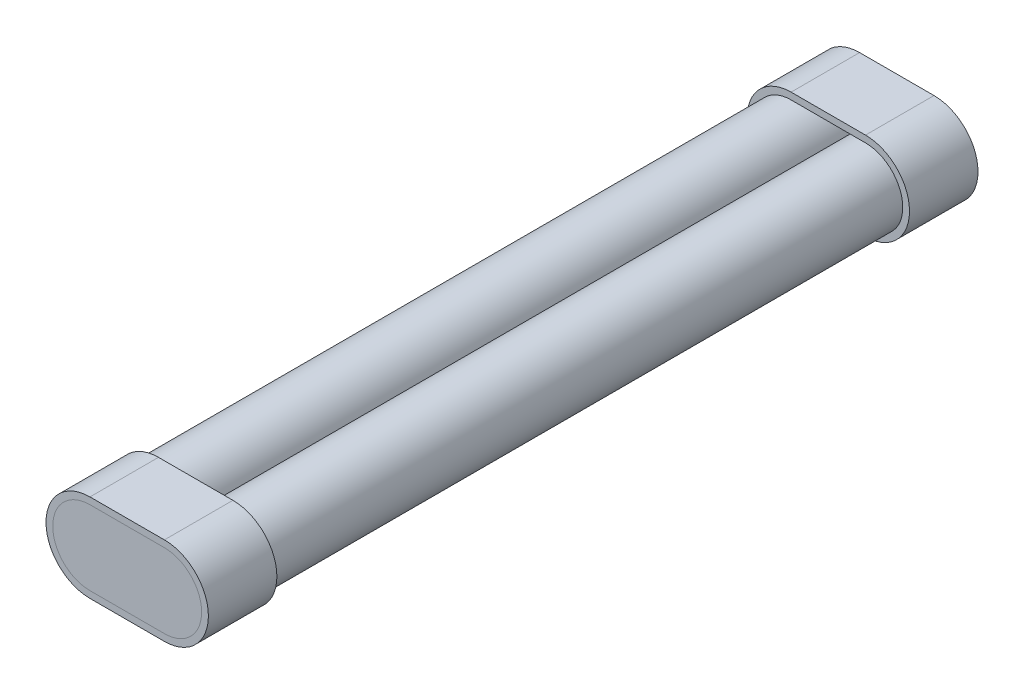
from build123d import *

# Parameters (mm, degrees)
ESQUISSE1_R              = 11
BOSS_EXTRU_2_DEPTH       = 223.5
BOSS_EXTRU_2_2_DEPTH     = 223.5
BOSS_EXTRU_8_DEPTH       = 2
BOSS_EXTRU_8_DEPTH_BACK  = 18.25
ESQUISSE1_6_R            = 11
BOSS_EXTRU_29_DEPTH      = 2
BOSS_EXTRU_33_DEPTH      = 2
BOSS_EXTRU_33_DEPTH_BACK = 18.25
BOSS_EXTRU_34_DEPTH      = 2


with BuildPart() as part:
    # Esquisse1 → Boss.-Extru.2 (new body)
    with BuildSketch(Plane.XY):
        with Locations((-11, 0)):
            Circle(ESQUISSE1_R)
    extrude(amount=-BOSS_EXTRU_2_DEPTH)


with BuildPart() as body_2:
    # Esquisse1 → Boss.-Extru.2 2 (new body)
    with BuildSketch(Plane.XY):
        with Locations((11, 0)):
            Circle(ESQUISSE1_R)
    extrude(amount=-BOSS_EXTRU_2_2_DEPTH)


with BuildPart() as body_3:
    # Esquisse1_5 → Boss.-Extru.8 (new body, two sides)
    with BuildSketch(Plane.XY) as boss_extru_8_sk:
        with BuildLine():
            Line((11, 13), (-11, 13))
            ThreePointArc((-11, 13), (-24, 0), (-11, -13))
            Line((-11, -13), (11, -13))
            ThreePointArc((11, -13), (24, 0), (11, 13))
        make_face()
        with BuildLine():
            Line((11, -11), (-11, -11))
            ThreePointArc((-11, -11), (-22, 0), (-11, 11))
            Line((-11, 11), (11, 11))
            ThreePointArc((11, 11), (18.778174593, 7.778174593), (22, 0))
            ThreePointArc((22, 0), (18.778174593, -7.778174593), (11, -11))
        make_face(mode=Mode.SUBTRACT)
    extrude(amount=BOSS_EXTRU_8_DEPTH)
    extrude(boss_extru_8_sk.sketch, amount=-BOSS_EXTRU_8_DEPTH_BACK)


with BuildPart() as body_4:
    # Esquisse1_6 → Boss.-Extru.29 (new body)
    with BuildSketch(Plane.XY):
        with Locations((-11, 0)):
            Circle(ESQUISSE1_6_R)
        with Locations((11, 0)):
            Circle(ESQUISSE1_6_R)
        with BuildLine():
            Line((11, 11), (-11, 11))
            ThreePointArc((-11, 11), (-3.221825407, 7.778174593), (0, 0))
            ThreePointArc((0, 0), (3.221825407, 7.778174593), (11, 11))
        make_face()
        with BuildLine():
            ThreePointArc((0, 0), (-3.221825407, -7.778174593), (-11, -11))
            Line((-11, -11), (11, -11))
            ThreePointArc((11, -11), (3.221825407, -7.778174593), (0, 0))
        make_face()
    extrude(amount=BOSS_EXTRU_29_DEPTH)


with BuildPart() as body_5:
    # Esquisse8 → Boss.-Extru.33 (new body, two sides)
    with BuildSketch(Plane(origin=(0, 0, -223.5), x_dir=(-1, 0, 0), z_dir=(0, 0, -1))) as boss_extru_33_sk:
        with BuildLine():
            Line((11, 13), (-11, 13))
            ThreePointArc((-11, 13), (-24, 0), (-11, -13))
            Line((-11, -13), (11, -13))
            ThreePointArc((11, -13), (24, 0), (11, 13))
        make_face()
        with BuildLine():
            Line((11, -11), (-11, -11))
            ThreePointArc((-11, -11), (-22, 0), (-11, 11))
            Line((-11, 11), (11, 11))
            ThreePointArc((11, 11), (18.778174593, 7.778174593), (22, 0))
            ThreePointArc((22, 0), (18.778174593, -7.778174593), (11, -11))
        make_face(mode=Mode.SUBTRACT)
    extrude(amount=BOSS_EXTRU_33_DEPTH)
    extrude(boss_extru_33_sk.sketch, amount=-BOSS_EXTRU_33_DEPTH_BACK)


with BuildPart() as body_6:
    # Esquisse8_3 → Boss.-Extru.34 (new body)
    with BuildSketch(Plane(origin=(0, 0, -223.5), x_dir=(-1, 0, 0), z_dir=(0, 0, -1))):
        with BuildLine():
            ThreePointArc((-11, 11), (-22, 0), (-11, -11))
            Line((-11, -11), (11, -11))
            ThreePointArc((11, -11), (22, 0), (11, 11))
            Line((11, 11), (-11, 11))
        make_face()
    extrude(amount=BOSS_EXTRU_34_DEPTH)


solid = Compound([part.part, body_2.part, body_3.part, body_4.part, body_5.part, body_6.part])
